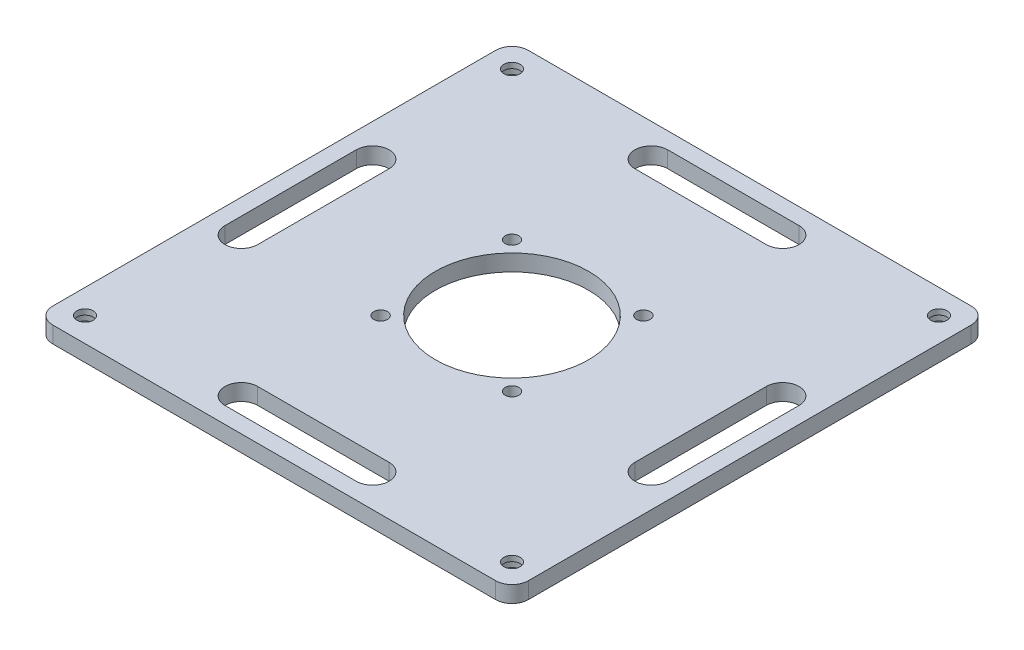
from build123d import *

# Parameters (mm, degrees)
SKETCH_1_W                     = 86.9
SKETCH_1_H                     = 86.9
EXTRUDE_1_DEPTH                = 3
HOLE_WIZARD_M2_5_1_D           = 3
HOLE_WIZARD_M2_5_1_DEPTH       = 3
HOLE_WIZARD_M2_5_1_CBORE_D     = 6
HOLE_WIZARD_M2_5_1_CBORE_DEPTH = 2
HOLE_WIZARD_2_0_2_1_D          = 2
HOLE_WIZARD_2_0_2_1_DEPTH      = 3
HOLE_WIZARD_2_5_2_5_1_D        = 2.5
HOLE_WIZARD_2_5_2_5_1_DEPTH    = 3
FILLET_1_R                     = 3
SKETCH_8_R                     = 14
CUT_EXTRUDE_1_DEPTH            = 4


with BuildPart() as part:
    # 草圖1 → 填料-伸長1 (new body)
    with BuildSketch(Plane(origin=(0, -37, 0), x_dir=(1, 0, 0), z_dir=(0, 1, 0))):
        Rectangle(SKETCH_1_W, SKETCH_1_H)
    extrude(amount=-EXTRUDE_1_DEPTH)

    # M2.5 六角頭機械螺釘的柱孔1
    with Locations(Plane(origin=(0, -40, 0), x_dir=(-1, 0, 0), z_dir=(0, -1, 0))):
        with Locations((39, 39), (-39, 39), (-39, -39), (39, -39)):
            CounterBoreHole(HOLE_WIZARD_M2_5_1_D / 2, HOLE_WIZARD_M2_5_1_CBORE_D / 2, HOLE_WIZARD_M2_5_1_CBORE_DEPTH, depth=HOLE_WIZARD_M2_5_1_DEPTH)

    # Ø2.0 (2) 直徑孔1
    with Locations(Plane(origin=(0, -37, 0), x_dir=(1, 0, 0), z_dir=(0, 1, 0))):
        with Locations((5, -10), (0, -10), (-5, -10), (-10, -5), (-10, 0), (-10, 5), (-5, 10), (0, 10), (5, 10), (10, 5), (10, 0), (10, -5), (5, -5), (0, -5), (-5, -5), (-5, 0), (-5, 5), (0, 5), (5, 5), (5, 0), (0, 0), (-37.5, 3), (-37.5, 0), (-37.5, -3), (3, 37.5), (0, 37.5), (-3, 37.5), (37.5, -3), (37.5, 0), (37.5, 3), (-3, -37.5), (0, -37.5), (3, -37.5)):
            Hole(HOLE_WIZARD_2_0_2_1_D / 2, depth=HOLE_WIZARD_2_0_2_1_DEPTH)

    # Ø2.5 (2.5) 直徑孔1
    with Locations(Plane(origin=(0, -40, 0), x_dir=(-1, 0, 0), z_dir=(0, -1, 0))):
        with Locations((12, 12), (-12, 12), (12, -12), (-12, -12)):
            Hole(HOLE_WIZARD_2_5_2_5_1_D / 2, depth=HOLE_WIZARD_2_5_2_5_1_DEPTH)

    # 圓角1
    fillet_1_edges = [part.edges().sort_by_distance(p)[0] for p in [
        (-43.45, -38.5, -43.45),
        (43.45, -38.5, -43.45),
        (43.45, -38.5, 43.45),
        (-43.45, -38.5, 43.45),
    ]]
    fillet(fillet_1_edges, radius=FILLET_1_R)

    # 草圖8 → 除料-伸長1 (cut, through all)
    with BuildSketch(Plane(origin=(0, -37, 0), x_dir=(1, 0, 0), z_dir=(0, 1, 0))):
        Circle(SKETCH_8_R)
        with BuildLine():
            Line((-40.45, -12), (-40.45, 12))
            ThreePointArc((-40.45, 12), (-37.45, 15), (-34.45, 12))
            Line((-34.45, 12), (-34.45, -12))
            ThreePointArc((-34.45, -12), (-37.45, -15), (-40.45, -12))
        make_face()
        with BuildLine():
            Line((-12, 40.45), (12, 40.45))
            ThreePointArc((12, 40.45), (15, 37.45), (12, 34.45))
            Line((12, 34.45), (-12, 34.45))
            ThreePointArc((-12, 34.45), (-15, 37.45), (-12, 40.45))
        make_face()
        with BuildLine():
            Line((40.45, 12), (40.45, -12))
            ThreePointArc((40.45, -12), (37.45, -15), (34.45, -12))
            Line((34.45, -12), (34.45, 12))
            ThreePointArc((34.45, 12), (37.45, 15), (40.45, 12))
        make_face()
        with BuildLine():
            Line((12, -40.45), (-12, -40.45))
            ThreePointArc((-12, -40.45), (-15, -37.45), (-12, -34.45))
            Line((-12, -34.45), (12, -34.45))
            ThreePointArc((12, -34.45), (15, -37.45), (12, -40.45))
        make_face()
    extrude(amount=-CUT_EXTRUDE_1_DEPTH, mode=Mode.SUBTRACT)


solid = part.part
